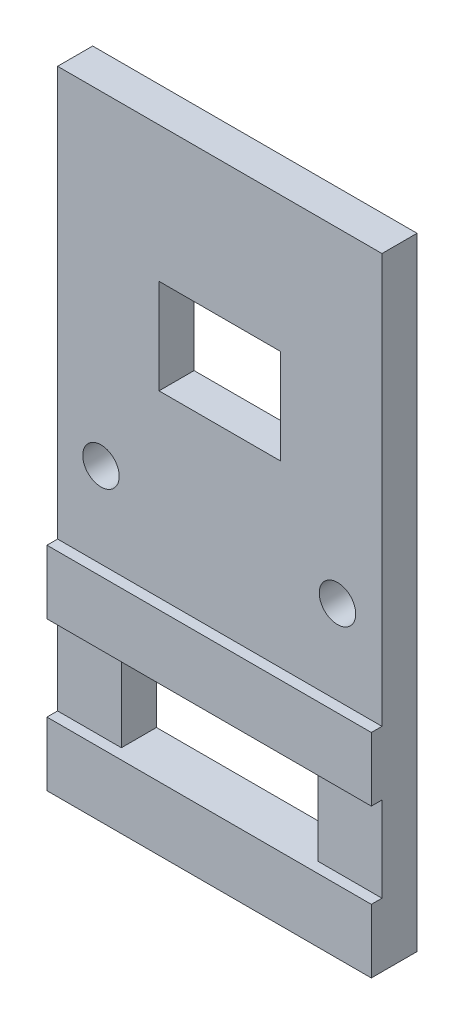
from build123d import *

# Parameters (mm, degrees)
SKETCH_1_W          = 30.50790567
SKETCH_1_H          = 58.511029644
SKETCH_1_R          = 1.716069694
SKETCH_1_W_2        = 11.42456148
SKETCH_1_H_2        = 8.922497171
EXTRUDE_1_DEPTH     = 3.3
SKETCH_2_W          = 30.50790567
SKETCH_2_H          = 6
EXTRUDE_2_DEPTH     = 1
SKETCH_3_W          = 18.50790567
SKETCH_3_H          = 8
CUT_EXTRUDE_1_DEPTH = 3.3


with BuildPart() as part:
    # 草圖1 → 填料-伸長1 (new body)
    with BuildSketch(Plane.XY):
        with Locations((0, 11.421692739)):
            Rectangle(SKETCH_1_W, SKETCH_1_H)
        with Locations((-11.174415212, 10.166177917)):
            Circle(SKETCH_1_R, mode=Mode.SUBTRACT)
        with Locations((11.070768934, 10.080826612)):
            Circle(SKETCH_1_R, mode=Mode.SUBTRACT)
        with Locations((0, 23.470612751)):
            Rectangle(SKETCH_1_W_2, SKETCH_1_H_2, mode=Mode.SUBTRACT)
    extrude(amount=EXTRUDE_1_DEPTH)

    # 草圖2 → 填料-伸長2 (add)
    with BuildSketch(Plane.XY.offset(3.3)):
        with Locations((0, -0.833822083)):
            Rectangle(SKETCH_2_W, SKETCH_2_H)
        with Locations((0, -14.833822083)):
            Rectangle(SKETCH_2_W, SKETCH_2_H)
    extrude(amount=EXTRUDE_2_DEPTH)

    # 草圖3 → 除料-伸長1 (cut)
    with BuildSketch(Plane.XY.offset(3.3)):
        with Locations((0, -7.833822083)):
            Rectangle(SKETCH_3_W, SKETCH_3_H)
    extrude(amount=-CUT_EXTRUDE_1_DEPTH, mode=Mode.SUBTRACT)


solid = part.part
